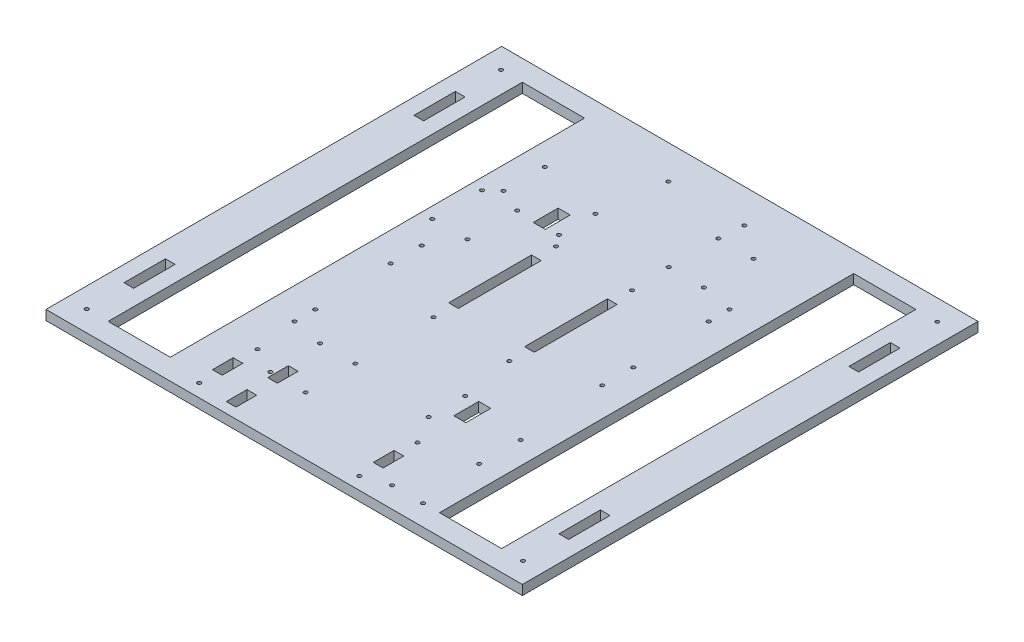
from build123d import *

# Parameters (mm, degrees)
SKETCH1_W           = 292.1
SKETCH1_H           = 279.4
BOSS_EXTRUDE1_DEPTH = 5.9436
SKETCH2_W           = 38.1
SKETCH2_H           = 254
SKETCH2_W_2         = 5.9309
SKETCH2_H_2         = 25.4
CUT_EXTRUDE1_DEPTH  = 6.9436
SKETCH5_R           = 1.1303
SKETCH5_W           = 7.366
SKETCH5_H           = 15.24
CUT_EXTRUDE2_DEPTH  = 6.9436
SKETCH7_R           = 1.1303
SKETCH7_W           = 5.9436
SKETCH7_H           = 12.7
CUT_EXTRUDE3_DEPTH  = 6.9436
SKETCH9_R           = 1.1303
CUT_EXTRUDE4_DEPTH  = 6.9436
SKETCH10_W          = 5.9436
SKETCH10_H          = 50.8
CUT_EXTRUDE5_DEPTH  = 6.9436
SKETCH12_R          = 1.1303
CUT_EXTRUDE6_DEPTH  = 6.9436


with BuildPart() as part:
    # Sketch1 → Boss-Extrude1 (new body)
    with BuildSketch(Plane(origin=(0, 0, 0), x_dir=(1, 0, 0), z_dir=(0, 1, 0))):
        Rectangle(SKETCH1_W, SKETCH1_H)
    extrude(amount=BOSS_EXTRUDE1_DEPTH)

    # Sketch2 → Cut-Extrude1 (cut, through all)
    with BuildSketch(Plane(origin=(0, 5.9436, 0), x_dir=(1, 0, 0), z_dir=(0, 1, 0))):
        with Locations((-101.6, 0)):
            Rectangle(SKETCH2_W, SKETCH2_H)
        with Locations((101.6, 0)):
            Rectangle(SKETCH2_W, SKETCH2_H)
        with Locations((133.35, 88.9)):
            Rectangle(SKETCH2_W_2, SKETCH2_H_2)
        with Locations((-133.35, 88.9)):
            Rectangle(SKETCH2_W_2, SKETCH2_H_2)
        with Locations((133.35, -88.9)):
            Rectangle(SKETCH2_W_2, SKETCH2_H_2)
        with Locations((-133.35, -88.9)):
            Rectangle(SKETCH2_W_2, SKETCH2_H_2)
    extrude(amount=-CUT_EXTRUDE1_DEPTH, mode=Mode.SUBTRACT)

    # Sketch5 → Cut-Extrude2 (cut, through all)
    with BuildSketch(Plane.XZ):
        with Locations((-43.99385, 104.14)):
            Circle(SKETCH5_R)
        with Locations((-22.40385, 104.14)):
            Circle(SKETCH5_R)
        with Locations((-43.99385, 73.66)):
            Circle(SKETCH5_R)
        with Locations((-22.40385, 73.66)):
            Circle(SKETCH5_R)
        with Locations((28.37815, 79.502)):
            Circle(SKETCH5_R)
        with Locations((28.37815, 57.15)):
            Circle(SKETCH5_R)
        with Locations((68.761578288, 88.9)):
            Circle(SKETCH5_R)
        with Locations((68.761578288, 63.5)):
            Circle(SKETCH5_R)
        with Locations((-63.5, 69.85)):
            Circle(SKETCH5_R)
        with Locations((44.00655, -73.66)):
            Circle(SKETCH5_R)
        with Locations((44.00655, -104.14)):
            Circle(SKETCH5_R)
        with Locations((22.41655, -104.14)):
            Circle(SKETCH5_R)
        with Locations((22.41655, -73.66)):
            Circle(SKETCH5_R)
        with Locations((-28.36545, -79.502)):
            Circle(SKETCH5_R)
        with Locations((-28.36545, -57.15)):
            Circle(SKETCH5_R)
        with Locations((-68.748878288, -63.5)):
            Circle(SKETCH5_R)
        with Locations((-68.748878288, -88.9)):
            Circle(SKETCH5_R)
        with Locations((-63.5, 57.15)):
            Circle(SKETCH5_R)
        with Locations((63.5, -69.85)):
            Circle(SKETCH5_R)
        with Locations((63.5, -57.15)):
            Circle(SKETCH5_R)
        with Locations((-64.77, 9.627315903)):
            Circle(SKETCH5_R)
        with Locations((-64.77, -9.422684097)):
            Circle(SKETCH5_R)
        with Locations((64.77, -9.610296009)):
            Circle(SKETCH5_R)
        with Locations((64.77, 9.439703991)):
            Circle(SKETCH5_R)
        with Locations((-133.7564, -127)):
            Circle(SKETCH5_R)
        with Locations((-133.7564, 127)):
            Circle(SKETCH5_R)
        with Locations((133.7564, -127)):
            Circle(SKETCH5_R)
        with Locations((133.7564, 127)):
            Circle(SKETCH5_R)
        with Locations((39.17315, 63.5)):
            Rectangle(SKETCH5_W, SKETCH5_H)
        with Locations((-39.16045, -63.5)):
            Rectangle(SKETCH5_W, SKETCH5_H)
    extrude(amount=-CUT_EXTRUDE2_DEPTH, mode=Mode.SUBTRACT)

    # Sketch7 → Cut-Extrude3 (cut, through all)
    with BuildSketch(Plane(origin=(0, 5.9436, 0), x_dir=(1, 0, 0), z_dir=(0, 1, 0))):
        with Locations((53.410346989, -127)):
            Circle(SKETCH7_R)
        with Locations((72.460346989, -127)):
            Circle(SKETCH7_R)
        with Locations((-60.069552222, -95.996553949)):
            Circle(SKETCH7_R)
        with Locations((-60.069552222, -131.742630767)):
            Circle(SKETCH7_R)
        with Locations((38.527322113, -96.482293749)):
            Circle(SKETCH7_R)
        with Locations((38.527322113, -132.062224084)):
            Circle(SKETCH7_R)
        with Locations((-60.059259893, -114.3)):
            Rectangle(SKETCH7_W, SKETCH7_H)
        with Locations((-38.875659893, -101.6)):
            Rectangle(SKETCH7_W, SKETCH7_H)
        with Locations((-38.875659893, -127)):
            Rectangle(SKETCH7_W, SKETCH7_H)
        with Locations((38.527322113, -114.207868653)):
            Rectangle(SKETCH7_W, SKETCH7_H)
    extrude(amount=-CUT_EXTRUDE3_DEPTH, mode=Mode.SUBTRACT)

    # Sketch9 → Cut-Extrude4 (cut, through all)
    with BuildSketch(Plane(origin=(0, 5.9436, 0), x_dir=(1, 0, 0), z_dir=(0, 1, 0))):
        with Locations((23.4442, 50.154484486)):
            Circle(SKETCH9_R)
        with Locations((23.4442, 119.039284486)):
            Circle(SKETCH9_R)
        with Locations((23.4442, -25.086665514)):
            Circle(SKETCH9_R)
        with Locations((-23.1394, 119.039284486)):
            Circle(SKETCH9_R)
        with Locations((-23.1394, 50.154484486)):
            Circle(SKETCH9_R)
        with Locations((-23.1394, -25.086665514)):
            Circle(SKETCH9_R)
    extrude(amount=-CUT_EXTRUDE4_DEPTH, mode=Mode.SUBTRACT)

    # Sketch10 → Cut-Extrude5 (cut, through all)
    with BuildSketch(Plane(origin=(0, 5.9436, 0), x_dir=(1, 0, 0), z_dir=(0, 1, 0))):
        with Locations((23.4442, 12.665075)):
            Rectangle(SKETCH10_W, SKETCH10_H)
        with Locations((-23.1394, 12.665075)):
            Rectangle(SKETCH10_W, SKETCH10_H)
    extrude(amount=-CUT_EXTRUDE5_DEPTH, mode=Mode.SUBTRACT)

    # Sketch12 → Cut-Extrude6 (cut, through all)
    with BuildSketch(Plane(origin=(0, 5.9436, 0), x_dir=(1, 0, 0), z_dir=(0, 1, 0))):
        with Locations((-75.6666, 26.7462)):
            Circle(SKETCH12_R)
        with Locations((-75.6666, 57.2262)):
            Circle(SKETCH12_R)
        with Locations((-54.0766, 57.2262)):
            Circle(SKETCH12_R)
        with Locations((-54.0766, 26.7462)):
            Circle(SKETCH12_R)
    extrude(amount=-CUT_EXTRUDE6_DEPTH, mode=Mode.SUBTRACT)


solid = part.part
